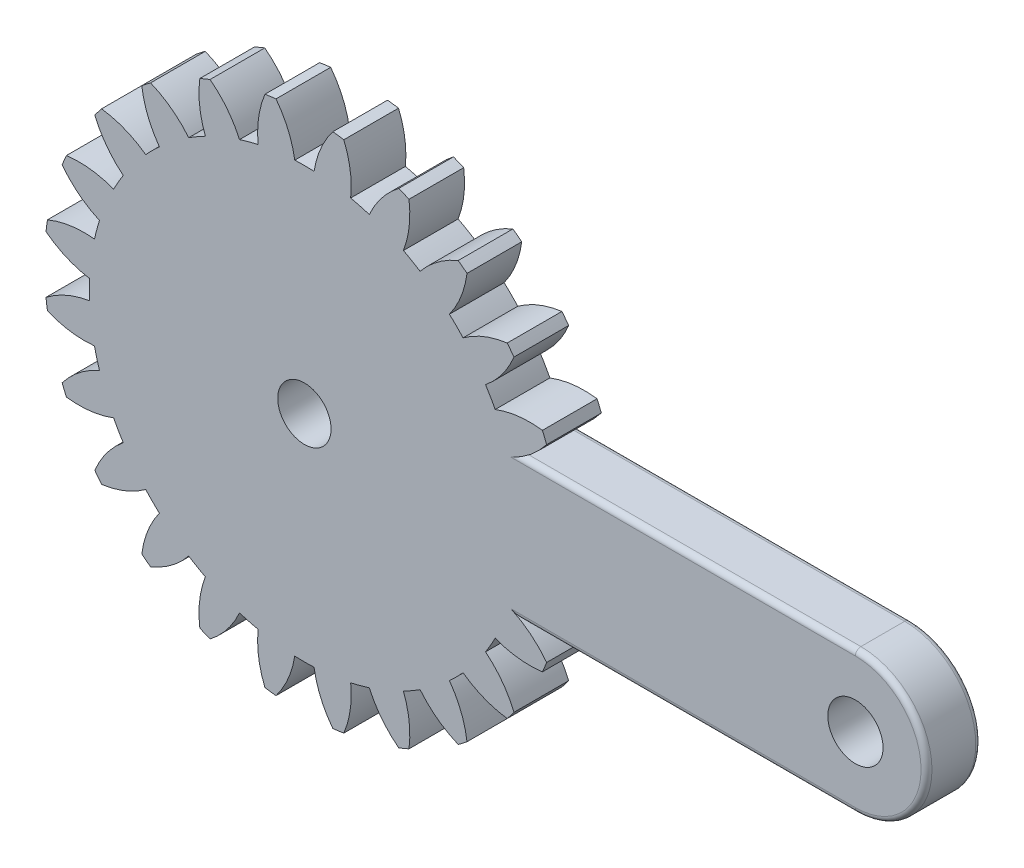
from build123d import *

# Parameters (mm, degrees)
SKETCH_1_R      = 5.05
SKETCH_1_R_2    = 4.875
EXTRUDE_1_DEPTH = 10
FILLET_1_R      = 1


with BuildPart() as part:
    # 草图1 → 凸台-拉伸1 (new body)
    with BuildSketch(Plane.XY):
        with BuildLine():
            Line((100.75, 13), (39.610949593, 13))
            ThreePointArc((39.610949593, 13), (42.143955384, 14.911655633), (44.291298968, 17.248204611))
            ThreePointArc((44.291298968, 17.248204611), (43.91314903, 18.189421895), (43.515000291, 19.122355404))
            ThreePointArc((43.515000291, 19.122355404), (39.135260233, 19.155630081), (34.883671922, 18.103381529))
            ThreePointArc((34.883671922, 18.103381529), (34.03604328, 19.65071875), (33.119824259, 21.158455298))
            ThreePointArc((33.119824259, 21.158455298), (36.156892392, 24.314314506), (38.317945706, 28.123917996))
            ThreePointArc((38.317945706, 28.123917996), (37.709075956, 28.935191673), (37.083032847, 29.733287767))
            ThreePointArc((37.083032847, 29.733287767), (32.843916692, 28.631868497), (29.009539705, 26.515082418))
            ThreePointArc((29.009539705, 26.515082418), (27.790312967, 27.790312967), (26.515082418, 29.009539705))
            ThreePointArc((26.515082418, 29.009539705), (28.631868497, 32.843916692), (29.733287767, 37.083032847))
            ThreePointArc((29.733287767, 37.083032847), (28.935191673, 37.709075956), (28.123917996, 38.317945706))
            ThreePointArc((28.123917996, 38.317945706), (24.314314506, 36.156892392), (21.158455298, 33.119824259))
            ThreePointArc((21.158455298, 33.119824259), (19.65071875, 34.03604328), (18.103381529, 34.883671922))
            ThreePointArc((18.103381529, 34.883671922), (19.155630081, 39.135260233), (19.122355404, 43.515000291))
            ThreePointArc((19.122355404, 43.515000291), (18.189421895, 43.91314903), (17.248204611, 44.291298968))
            ThreePointArc((17.248204611, 44.291298968), (14.127731967, 41.217883822), (11.865457128, 37.46750481))
            ThreePointArc((11.865457128, 37.46750481), (10.171960525, 37.962273492), (8.457965105, 38.380539546))
            ThreePointArc((8.457965105, 38.380539546), (8.37396713, 42.759600464), (7.208266121, 46.981492378))
            ThreePointArc((7.208266121, 46.981492378), (6.204073074, 47.124613567), (5.197054586, 47.2462734))
            ThreePointArc((5.197054586, 47.2462734), (2.978367841, 43.469944586), (1.763847663, 39.261836826))
            ThreePointArc((1.763847663, 39.261836826), (0, 39.3014375), (-1.763847663, 39.261836826))
            ThreePointArc((-1.763847663, 39.261836826), (-2.978367841, 43.469944586), (-5.197054586, 47.2462734))
            ThreePointArc((-5.197054586, 47.2462734), (-6.204073074, 47.124613567), (-7.208266121, 46.981492378))
            ThreePointArc((-7.208266121, 46.981492378), (-8.37396713, 42.759600464), (-8.457965105, 38.380539546))
            ThreePointArc((-8.457965105, 38.380539546), (-10.171960525, 37.962273492), (-11.865457128, 37.46750481))
            ThreePointArc((-11.865457128, 37.46750481), (-14.127731967, 41.217883822), (-17.248204611, 44.291298968))
            ThreePointArc((-17.248204611, 44.291298968), (-18.189421895, 43.91314903), (-19.122355404, 43.515000291))
            ThreePointArc((-19.122355404, 43.515000291), (-19.155630081, 39.135260233), (-18.103381529, 34.883671922))
            ThreePointArc((-18.103381529, 34.883671922), (-19.65071875, 34.03604328), (-21.158455298, 33.119824259))
            ThreePointArc((-21.158455298, 33.119824259), (-24.314314506, 36.156892392), (-28.123917996, 38.317945706))
            ThreePointArc((-28.123917996, 38.317945706), (-28.935191673, 37.709075956), (-29.733287767, 37.083032847))
            ThreePointArc((-29.733287767, 37.083032847), (-28.631868497, 32.843916692), (-26.515082418, 29.009539705))
            ThreePointArc((-26.515082418, 29.009539705), (-27.790312967, 27.790312967), (-29.009539705, 26.515082418))
            ThreePointArc((-29.009539705, 26.515082418), (-32.843916692, 28.631868497), (-37.083032847, 29.733287767))
            ThreePointArc((-37.083032847, 29.733287767), (-37.709075956, 28.935191673), (-38.317945706, 28.123917996))
            ThreePointArc((-38.317945706, 28.123917996), (-36.156892392, 24.314314506), (-33.119824259, 21.158455298))
            ThreePointArc((-33.119824259, 21.158455298), (-34.03604328, 19.65071875), (-34.883671922, 18.103381529))
            ThreePointArc((-34.883671922, 18.103381529), (-39.135260233, 19.155630081), (-43.515000291, 19.122355404))
            ThreePointArc((-43.515000291, 19.122355404), (-43.91314903, 18.189421895), (-44.291298968, 17.248204611))
            ThreePointArc((-44.291298968, 17.248204611), (-41.217883822, 14.127731967), (-37.46750481, 11.865457128))
            ThreePointArc((-37.46750481, 11.865457128), (-37.962273492, 10.171960525), (-38.380539546, 8.457965105))
            ThreePointArc((-38.380539546, 8.457965105), (-42.759600464, 8.37396713), (-46.981492378, 7.208266121))
            ThreePointArc((-46.981492378, 7.208266121), (-47.124613567, 6.204073074), (-47.2462734, 5.197054586))
            ThreePointArc((-47.2462734, 5.197054586), (-43.469944586, 2.978367841), (-39.261836826, 1.763847663))
            ThreePointArc((-39.261836826, 1.763847663), (-39.3014375, 0), (-39.261836826, -1.763847663))
            ThreePointArc((-39.261836826, -1.763847663), (-43.469944586, -2.978367841), (-47.2462734, -5.197054586))
            ThreePointArc((-47.2462734, -5.197054586), (-47.124613567, -6.204073074), (-46.981492378, -7.208266121))
            ThreePointArc((-46.981492378, -7.208266121), (-42.759600464, -8.37396713), (-38.380539546, -8.457965105))
            ThreePointArc((-38.380539546, -8.457965105), (-37.962273492, -10.171960525), (-37.46750481, -11.865457128))
            ThreePointArc((-37.46750481, -11.865457128), (-41.217883822, -14.127731967), (-44.291298968, -17.248204611))
            ThreePointArc((-44.291298968, -17.248204611), (-43.91314903, -18.189421895), (-43.515000291, -19.122355404))
            ThreePointArc((-43.515000291, -19.122355404), (-39.135260233, -19.155630081), (-34.883671922, -18.103381529))
            ThreePointArc((-34.883671922, -18.103381529), (-34.03604328, -19.65071875), (-33.119824259, -21.158455298))
            ThreePointArc((-33.119824259, -21.158455298), (-36.156892392, -24.314314506), (-38.317945706, -28.123917996))
            ThreePointArc((-38.317945706, -28.123917996), (-37.709075956, -28.935191673), (-37.083032847, -29.733287767))
            ThreePointArc((-37.083032847, -29.733287767), (-32.843916692, -28.631868497), (-29.009539705, -26.515082418))
            ThreePointArc((-29.009539705, -26.515082418), (-27.790312967, -27.790312967), (-26.515082418, -29.009539705))
            ThreePointArc((-26.515082418, -29.009539705), (-28.631868497, -32.843916692), (-29.733287767, -37.083032847))
            ThreePointArc((-29.733287767, -37.083032847), (-28.935191673, -37.709075956), (-28.123917996, -38.317945706))
            ThreePointArc((-28.123917996, -38.317945706), (-24.314314506, -36.156892392), (-21.158455298, -33.119824259))
            ThreePointArc((-21.158455298, -33.119824259), (-19.65071875, -34.03604328), (-18.103381529, -34.883671922))
            ThreePointArc((-18.103381529, -34.883671922), (-19.155630081, -39.135260233), (-19.122355404, -43.515000291))
            ThreePointArc((-19.122355404, -43.515000291), (-18.189421895, -43.91314903), (-17.248204611, -44.291298968))
            ThreePointArc((-17.248204611, -44.291298968), (-14.127731967, -41.217883822), (-11.865457128, -37.46750481))
            ThreePointArc((-11.865457128, -37.46750481), (-10.171960525, -37.962273492), (-8.457965105, -38.380539546))
            ThreePointArc((-8.457965105, -38.380539546), (-8.37396713, -42.759600464), (-7.208266121, -46.981492378))
            ThreePointArc((-7.208266121, -46.981492378), (-6.204073074, -47.124613567), (-5.197054586, -47.2462734))
            ThreePointArc((-5.197054586, -47.2462734), (-2.978367841, -43.469944586), (-1.763847663, -39.261836826))
            ThreePointArc((-1.763847663, -39.261836826), (0, -39.3014375), (1.763847663, -39.261836826))
            ThreePointArc((1.763847663, -39.261836826), (2.978367841, -43.469944586), (5.197054586, -47.2462734))
            ThreePointArc((5.197054586, -47.2462734), (6.204073074, -47.124613567), (7.208266121, -46.981492378))
            ThreePointArc((7.208266121, -46.981492378), (8.37396713, -42.759600464), (8.457965105, -38.380539546))
            ThreePointArc((8.457965105, -38.380539546), (10.171960525, -37.962273492), (11.865457128, -37.46750481))
            ThreePointArc((11.865457128, -37.46750481), (14.127731967, -41.217883822), (17.248204611, -44.291298968))
            ThreePointArc((17.248204611, -44.291298968), (18.189421895, -43.91314903), (19.122355404, -43.515000291))
            ThreePointArc((19.122355404, -43.515000291), (19.155630081, -39.135260233), (18.103381529, -34.883671922))
            ThreePointArc((18.103381529, -34.883671922), (19.65071875, -34.03604328), (21.158455298, -33.119824259))
            ThreePointArc((21.158455298, -33.119824259), (24.314314506, -36.156892392), (28.123917996, -38.317945706))
            ThreePointArc((28.123917996, -38.317945706), (28.935191673, -37.709075956), (29.733287767, -37.083032847))
            ThreePointArc((29.733287767, -37.083032847), (28.631868497, -32.843916692), (26.515082418, -29.009539705))
            ThreePointArc((26.515082418, -29.009539705), (27.790312967, -27.790312967), (29.009539705, -26.515082418))
            ThreePointArc((29.009539705, -26.515082418), (32.843916692, -28.631868497), (37.083032847, -29.733287767))
            ThreePointArc((37.083032847, -29.733287767), (37.709075956, -28.935191673), (38.317945706, -28.123917996))
            ThreePointArc((38.317945706, -28.123917996), (36.156892392, -24.314314506), (33.119824259, -21.158455298))
            ThreePointArc((33.119824259, -21.158455298), (34.03604328, -19.65071875), (34.883671922, -18.103381529))
            ThreePointArc((34.883671922, -18.103381529), (39.135260233, -19.155630081), (43.515000291, -19.122355404))
            ThreePointArc((43.515000291, -19.122355404), (43.91314903, -18.189421895), (44.291298968, -17.248204611))
            ThreePointArc((44.291298968, -17.248204611), (42.143955384, -14.911655633), (39.610949593, -13))
            Line((39.610949593, -13), (100.75, -13))
            ThreePointArc((100.75, -13), (113.75, 0), (100.75, 13))
        make_face()
        with Locations((100.75, 0)):
            Circle(SKETCH_1_R, mode=Mode.SUBTRACT)
        Circle(SKETCH_1_R_2, mode=Mode.SUBTRACT)
    extrude(amount=EXTRUDE_1_DEPTH)

    # 圆角1
    fillet_1_edges = [part.edges().sort_by_distance(p)[0] for p in [
        (70.180474796, 13, 0),
        (113.75, 0, 0),
        (70.180474796, -13, 10),
        (113.75, 0, 10),
        (70.180474796, -13, 0),
        (70.180474796, 13, 10),
    ]]
    fillet(fillet_1_edges, radius=FILLET_1_R)


solid = part.part
